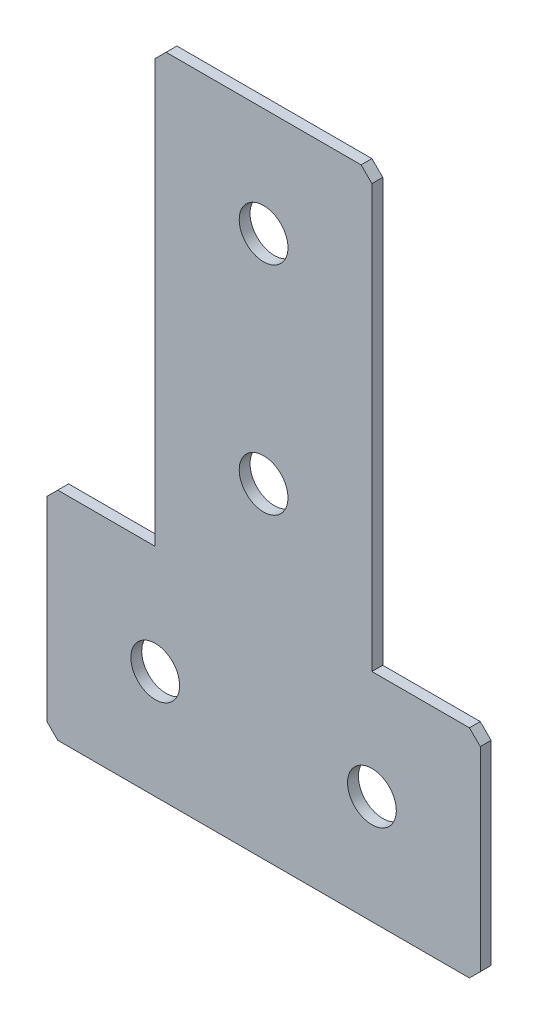
from build123d import *

# Parameters (mm, degrees)
EXTRUDE_1_DEPTH   = 2
HOLE_WIZARD_M81_D = 9
CHAMFER_1_SIZE    = 2


with BuildPart() as part:
    # Эскиз1 → Бобышка-Вытянуть1 (new body)
    with BuildSketch(Plane(origin=(0, 0, 0), x_dir=(1, 0, 0), z_dir=(0, 0, -1))):
        Polygon((-40, 120), (40, 120), (40, 80), (20, 80), (20, 0), (-20, 0), (-20, 80), (-40, 80), align=None)
    extrude(amount=EXTRUDE_1_DEPTH)

    # Отверстие с зазором M81 (through all)
    with Locations(Plane(origin=(0, 0, -2), x_dir=(1, 0, 0), z_dir=(0, 0, -1))):
        with Locations((20, 100), (0, 60), (0, 20), (-20, 100)):
            Hole(HOLE_WIZARD_M81_D / 2)

    # Фаска1
    chamfer_1_edges = [part.edges().sort_by_distance(p)[0] for p in [
        (-40, -80, -1),
        (-40, -120, -1),
        (40, -120, -1),
        (40, -80, -1),
        (20, 0, -1),
        (-20, 0, -1),
    ]]
    chamfer(chamfer_1_edges, length=CHAMFER_1_SIZE)


solid = part.part
